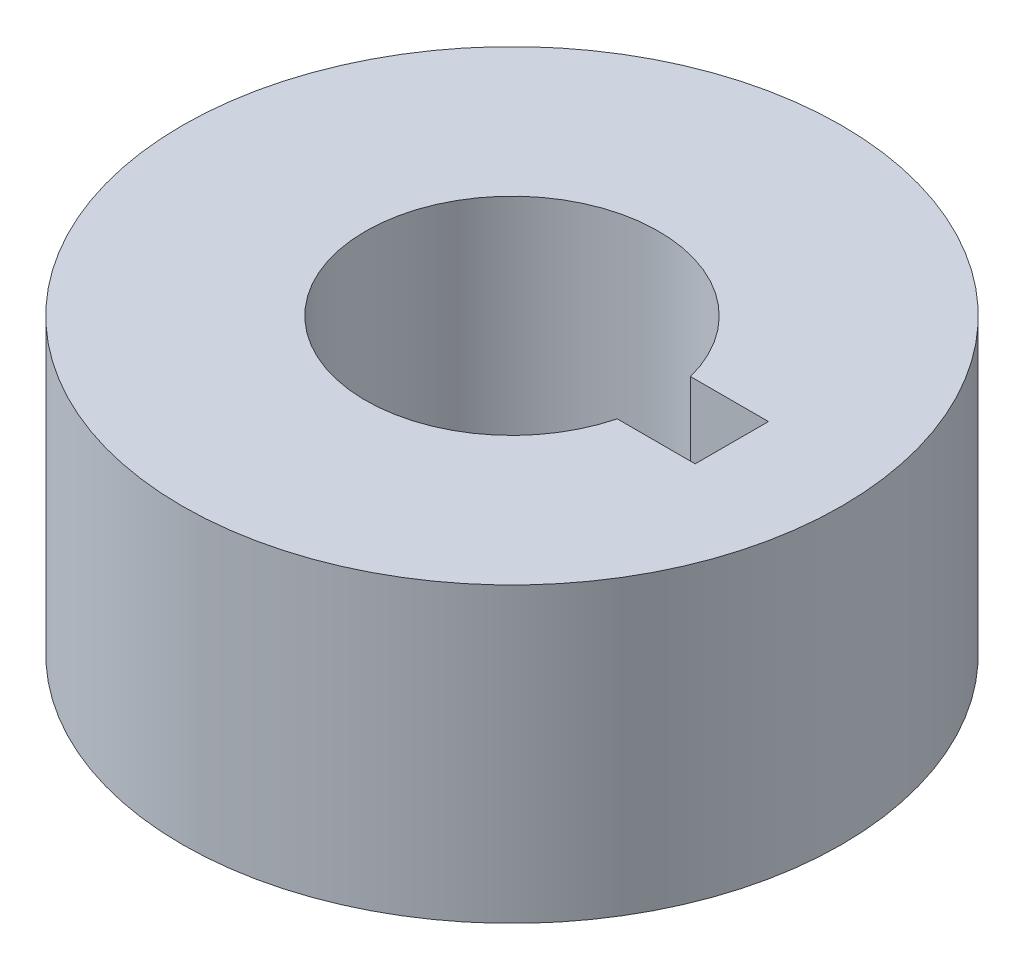
from build123d import *

# Parameters (mm, degrees)
SKETCH1_R           = 22.5
BOSS_EXTRUDE1_DEPTH = 20
CUT_EXTRUDE2_DEPTH  = 20


with BuildPart() as part:
    # Sketch1 → Boss-Extrude1 (new body)
    with BuildSketch(Plane(origin=(0, 0, 0), x_dir=(1, 0, 0), z_dir=(0, 1, 0))):
        Circle(SKETCH1_R)
    extrude(amount=BOSS_EXTRUDE1_DEPTH)

    # Sketch2 → Cut-Extrude2 (cut)
    with BuildSketch(Plane(origin=(0, 20, 0), x_dir=(1, 0, 0), z_dir=(0, 1, 0))):
        with BuildLine():
            Line((5, -2.5), (5, 2.5))
            Line((5, 2.5), (9.682458366, 2.5))
            ThreePointArc((9.682458366, 2.5), (-10, 0), (9.682458366, -2.5))
            Line((9.682458366, -2.5), (5, -2.5))
        make_face()
        with BuildLine():
            Line((9.682458366, 2.5), (5, 2.5))
            Line((5, 2.5), (5, -2.5))
            Line((5, -2.5), (9.682458366, -2.5))
            ThreePointArc((9.682458366, -2.5), (9.920296963, -1.260042925), (10, 0))
            ThreePointArc((10, 0), (9.920296963, 1.260042925), (9.682458366, 2.5))
        make_face()
        with BuildLine():
            Line((15, 2.5), (9.682458366, 2.5))
            ThreePointArc((9.682458366, 2.5), (9.920296963, 1.260042925), (10, 0))
            ThreePointArc((10, 0), (9.920296963, -1.260042925), (9.682458366, -2.5))
            Line((9.682458366, -2.5), (15, -2.5))
            Line((15, -2.5), (15, 2.5))
        make_face()
    extrude(amount=-CUT_EXTRUDE2_DEPTH, mode=Mode.SUBTRACT)


solid = part.part
